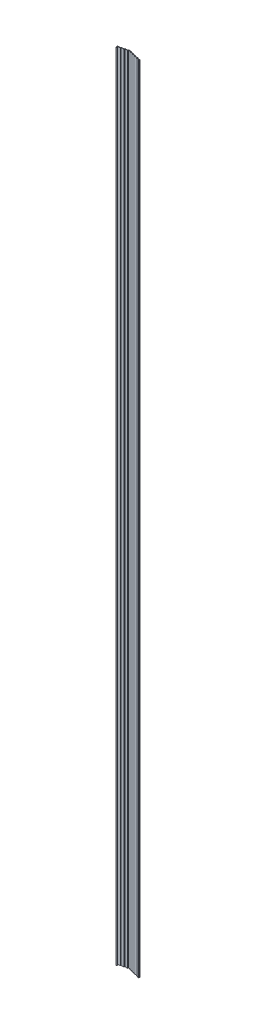
from build123d import *

# Parameters (mm, degrees)
BOSS_EXTRUDE1_DEPTH = 3505.2
CUT_EXTRUDE1_DEPTH  = 3506.2
BOSS_EXTRUDE2_DEPTH = 3505.2
FILLET1_R           = 0.508


with BuildPart() as part:
    # Sketch1 → Boss-Extrude1 (new body)
    with BuildSketch(Plane(origin=(0, 0, 0), x_dir=(1, 0, 0), z_dir=(0, 1, 0))):
        Polygon((0, 9.525), (0, 8.001), (1.524, 8.001), (1.524, 11.176), (14.222095, 11.176), (14.222095, 14.351), (26.92019, 14.351), (26.92019, 17.526), (36.570285, 17.526), (36.570285, 14.351), (49.26838, 14.351), (49.26838, 11.176), (61.966475, 11.176), (61.966475, 8.001), (74.66457, 8.001), (74.66457, 4.826), (88.886665, 4.826), (88.886665, 6.35), (76.18857, 6.35), (76.18857, 9.525), (63.490475, 9.525), (63.490475, 12.7), (50.79238, 12.7), (50.79238, 15.875), (38.094285, 15.875), (38.094285, 19.05), (25.39619, 19.05), (25.39619, 15.875), (12.698095, 15.875), (12.698095, 12.7), (0, 12.7), align=None)
        Polygon((-11.176, 8.001), (0, 8.001), (0, 9.525), (-12.7, 9.525), (-12.7, 4.826), (-11.176, 4.826), align=None)
    extrude(amount=BOSS_EXTRUDE1_DEPTH)

    # Sketch2 → Cut-Extrude1 (cut, through all)
    with BuildSketch(Plane(origin=(0, 3505.2, 0), x_dir=(1, 0, 0), z_dir=(0, 1, 0))):
        Polygon((88.886665, 5.588), (88.609319681, 4.826), (88.886665, 4.826), align=None)
        Polygon((-12.7, 5.588), (-12.422654681, 4.826), (-12.7, 4.826), align=None)
    extrude(amount=-CUT_EXTRUDE1_DEPTH, mode=Mode.SUBTRACT)

    # Sketch3 → Boss-Extrude2 (add, through all)
    with BuildSketch(Plane(origin=(0, 3505.2, 0), x_dir=(1, 0, 0), z_dir=(0, 1, 0))):
        with BuildLine():
            Line((-12.422654681, 4.826), (-12.353318352, 4.6355))
            Line((-12.353318352, 4.6355), (-9.906, 4.6355))
            ThreePointArc((-9.906, 4.6355), (-8.6995, 3.429), (-9.906, 2.2225))
            Line((-9.906, 2.2225), (-10.930933786, 2.2225))
            ThreePointArc((-10.930933786, 2.2225), (-11.243030715, 2.060032622), (-11.288956675, 1.711190325))
            Line((-11.288956675, 1.711190325), (-11.06251152, 1.089037376))
            ThreePointArc((-11.06251152, 1.089037376), (-10.973585853, 0.949629263), (-10.833973274, 0.861024951))
            ThreePointArc((-10.833973274, 0.861024951), (-7.216438129, 2.957950969), (-9.906, 6.1595))
            Line((-9.906, 6.1595), (-10.414, 6.1595))
            ThreePointArc((-10.414, 6.1595), (-10.952815367, 6.382684633), (-11.176, 6.9215))
            Line((-11.176, 6.9215), (-11.176, 4.826))
            Line((-11.176, 4.826), (-12.422654681, 4.826))
        make_face()
        with BuildLine():
            Line((87.458476675, 1.711190325), (87.23203152, 1.089037376))
            ThreePointArc((87.23203152, 1.089037376), (87.143105853, 0.949629263), (87.003493274, 0.861024951))
            ThreePointArc((87.003493274, 0.861024951), (84.395043041, 1.276878387), (83.359175913, 3.706677966))
            ThreePointArc((83.359175913, 3.706677966), (83.10250927, 4.490911453), (82.34844323, 4.826))
            Line((82.34844323, 4.826), (88.609319681, 4.826))
            Line((88.609319681, 4.826), (88.522838352, 4.6355))
            Line((88.522838352, 4.6355), (86.07552, 4.6355))
            ThreePointArc((86.07552, 4.6355), (84.86902, 3.429), (86.07552, 2.2225))
            Line((86.07552, 2.2225), (87.100453786, 2.2225))
            ThreePointArc((87.100453786, 2.2225), (87.412550715, 2.060032622), (87.458476675, 1.711190325))
        make_face()
    extrude(amount=-BOSS_EXTRUDE2_DEPTH)

    # Fillet1
    fillet1_edges = [part.edges().sort_by_distance(p)[0] for p in [
        (88.522838352, 1752.6, -4.6355),
        (-12.353318352, 1752.6, -4.6355),
    ]]
    fillet(fillet1_edges, radius=FILLET1_R)


solid = part.part
